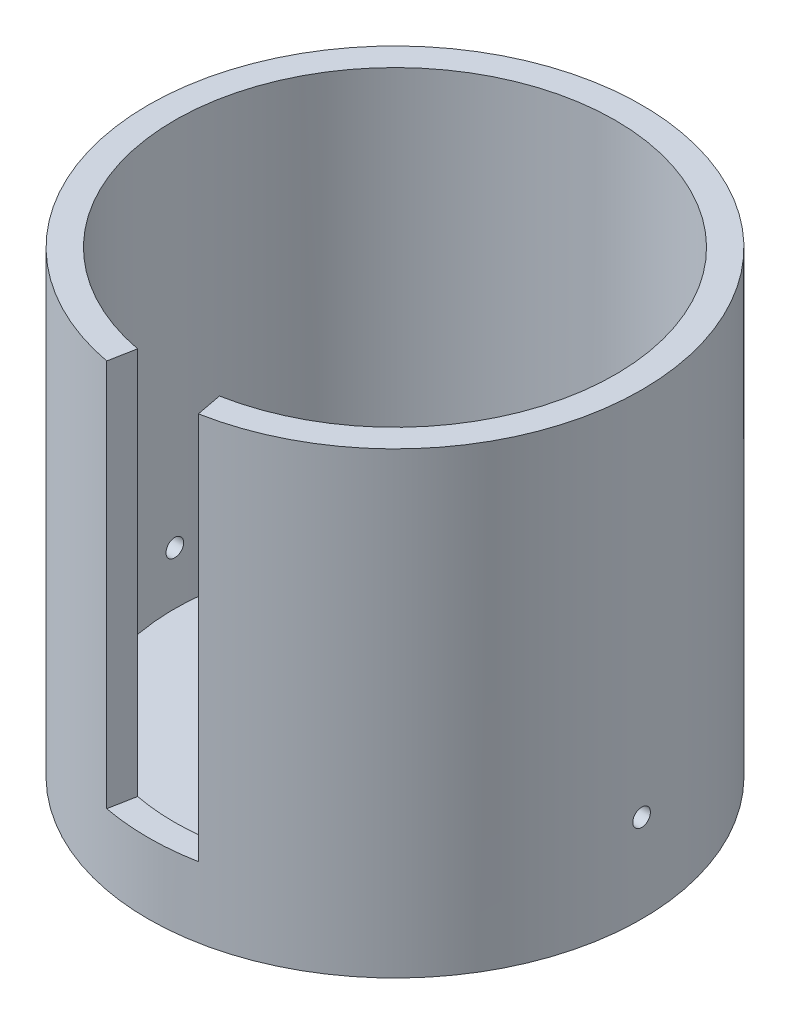
from build123d import *

# Parameters (mm, degrees)
SKETCH_235_R             = 70
EXTRUDE_1_DEPTH          = 130
SKETCH_315_R             = 62.5
CUT_EXTRUDE_1_DEPTH      = 120
CUT_EXTRUDE_2_DEPTH      = 110
SKETCH_5_R               = 35
CUT_EXTRUDE_3_DEPTH      = 110
SKETCH_9_R               = 2.5
CUT_EXTRUDE_5_DEPTH      = 30
PATTERN_CIRCULAR_2_COUNT = 4


with BuildPart() as part:
    # Sketch 235 → Бобышка-Вытянуть1 (new body)
    with BuildSketch(Plane(origin=(0, 0, 0), x_dir=(1, 0, 0), z_dir=(0, 1, 0))):
        Circle(SKETCH_235_R)
    extrude(amount=EXTRUDE_1_DEPTH)

    # Sketch 315 → Вырез-Вытянуть1 (cut)
    with BuildSketch(Plane(origin=(0, 130, 0), x_dir=(1, 0, 0), z_dir=(0, 1, 0))):
        Circle(SKETCH_315_R)
    extrude(amount=-CUT_EXTRUDE_1_DEPTH, mode=Mode.SUBTRACT)

    # Sketch 408 → Вырез-Вытянуть2 (cut)
    with BuildSketch(Plane(origin=(0, 130, 0), x_dir=(1, 0, 0), z_dir=(0, 1, 0))):
        Polygon((-11.607142857, -61.412736746), (-13, -68.782265156), (0, -74.034115552), (13, -68.782265156), (11.607142857, -61.412736746), align=None)
    extrude(amount=-CUT_EXTRUDE_2_DEPTH, mode=Mode.SUBTRACT)

    # Эскиз5 → Вырез-Вытянуть3 (cut)
    with BuildSketch(Plane.XZ):
        Circle(SKETCH_5_R)
    extrude(amount=-CUT_EXTRUDE_3_DEPTH, mode=Mode.SUBTRACT)

    # Эскиз9 → Вырез-Вытянуть5 (cut)
    with BuildSketch(Plane(origin=(70, 0, 0), x_dir=(0, 0, -1), z_dir=(1, 0, 0))):
        with Locations((0, 25)):
            Circle(SKETCH_9_R)
    cut_extrude_5 = extrude(amount=-CUT_EXTRUDE_5_DEPTH, mode=Mode.SUBTRACT)

    # Круговой массив2: Вырез-Вытянуть5 ×4 about axis
    pattern_circular_2_axis = Axis((0, -1.889670697, 0), (0, 1, 0))
    for i in range(1, PATTERN_CIRCULAR_2_COUNT):
        add(cut_extrude_5.rotate(pattern_circular_2_axis, i * 360 / PATTERN_CIRCULAR_2_COUNT), mode=Mode.SUBTRACT)


solid = part.part
